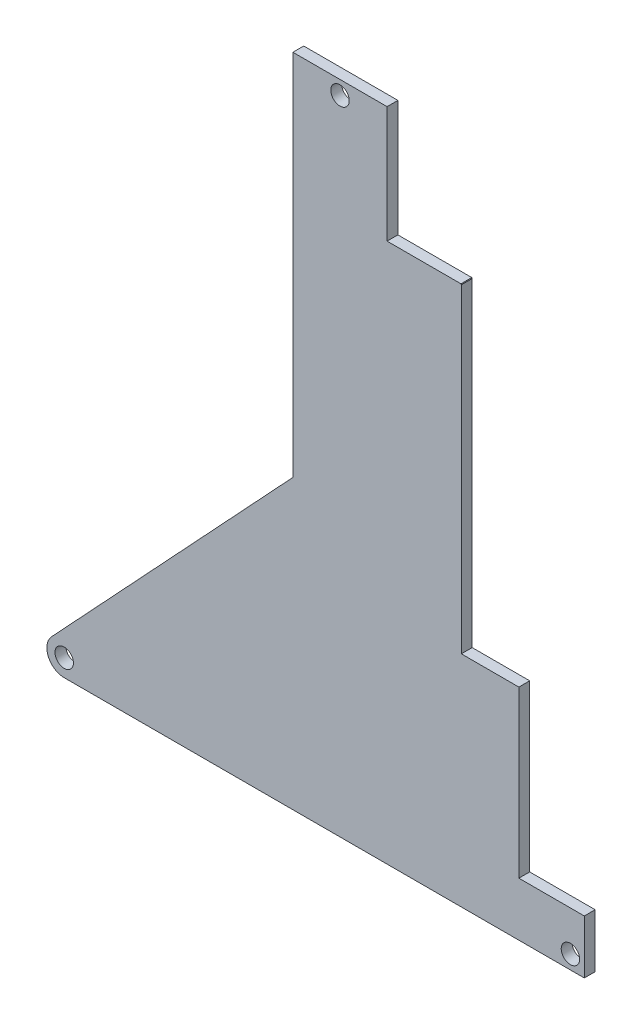
from build123d import *

# Parameters (mm, degrees)
BOSS_EXTRUDE1_DEPTH   = 1.5875
F_2_CLEARANCE_HOLE1_D = 2.7051
CUT_EXTRUDE1_DEPTH    = 2.5875


with BuildPart() as part:
    # Sketch1 → Boss-Extrude1 (new body)
    with BuildSketch(Plane.XY):
        with BuildLine():
            Line((-52.648603939, -67.272400153), (-30.578425, -43.620868829))
            Line((-30.578425, -43.620868829), (-18.837275, -31.03845263))
            Line((-18.837275, -31.03845263), (-18.837275, 15.096748243))
            Line((-18.837275, 15.096748243), (-18.837275, 22.917825485))
            Line((-18.837275, 22.917825485), (-5.036497092, 22.917825485))
            ThreePointArc((-5.036497092, 22.917825485), (16.456769026, -18.908795935), (23.866475, -65.347174515))
            Line((23.866475, -65.347174515), (23.866475, -73.221174515))
            Line((23.866475, -73.221174515), (-30.578425, -73.221174515))
            Line((-30.578425, -73.221174515), (-52.355372399, -73.221174515))
            ThreePointArc((-52.355372399, -73.221174515), (-54.684874047, -71.693608254), (-54.212432291, -68.948278512))
            Line((-54.212432291, -68.948278512), (-52.648603939, -67.272400153))
        make_face()
    extrude(amount=BOSS_EXTRUDE1_DEPTH)

    # #2 Clearance Hole1 (through all)
    with Locations(Plane(origin=(0, 0, 0), x_dir=(-1, 0, 0), z_dir=(0, 0, -1))):
        with Locations((-21.834475, -71.189174515), (52.355372399, -70.681174515), (11.936886046, 20.885825485)):
            Hole(F_2_CLEARANCE_HOLE1_D / 2)

    # Sketch4 → Cut-Extrude1 (cut, through all)
    with BuildSketch(Plane(origin=(0, 0, 0), x_dir=(-1, 0, 0), z_dir=(0, 0, -1))):
        with BuildLine():
            ThreePointArc((-21.881749979, -41.090174515), (-23.369466076, -53.178144332), (-23.866475, -65.347174515))
            Line((-23.866475, -65.347174515), (-14.277975, -65.347174515))
            Line((-14.277975, -65.347174515), (-14.277975, -41.090174515))
            Line((-14.277975, -41.090174515), (-21.881749979, -41.090174515))
        make_face()
        with BuildLine():
            ThreePointArc((-5.845175, 5.742133621), (-15.818945129, -17.004413391), (-21.881749979, -41.090174515))
            Line((-21.881749979, -41.090174515), (-14.277975, -41.090174515))
            Line((-14.277975, -41.090174515), (-5.845175, -41.090174515))
            Line((-5.845175, -41.090174515), (-5.845175, 5.742133621))
        make_face()
        with BuildLine():
            ThreePointArc((5.036497092, 22.917825485), (-0.665836205, 14.565033613), (-5.789292349, 5.845175))
            Line((-5.789292349, 5.845175), (5.036497092, 5.845175))
            Line((5.036497092, 5.845175), (5.036497092, 22.917825485))
        make_face()
    extrude(amount=-CUT_EXTRUDE1_DEPTH, mode=Mode.SUBTRACT)


solid = part.part
